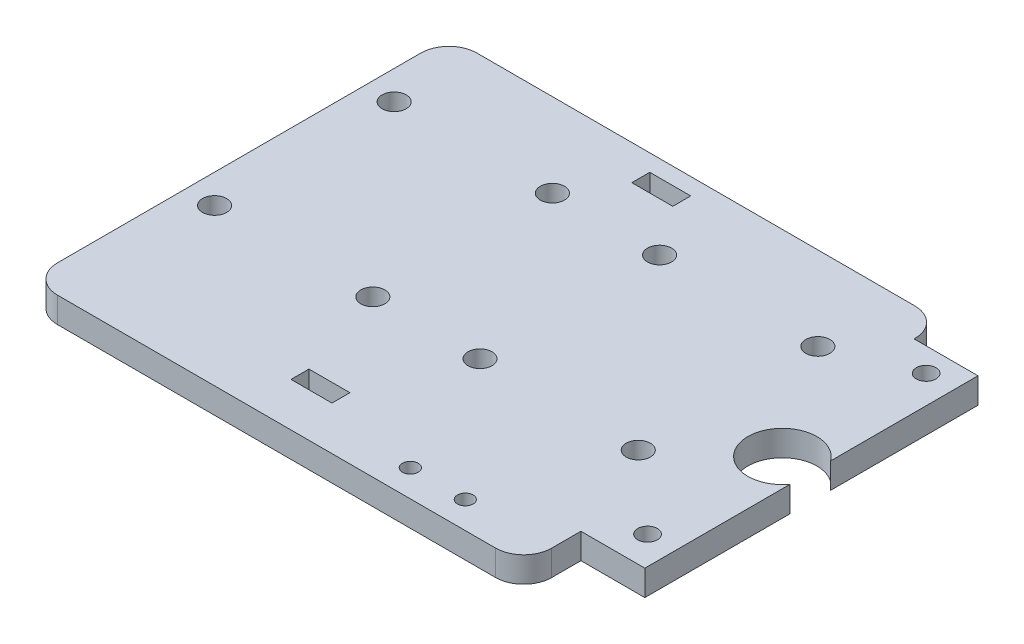
from build123d import *

# Parameters (mm, degrees)
SKETCH1_R           = 2.15
SKETCH1_R_2         = 6.15
SKETCH1_R_3         = 1.75
SKETCH1_R_4         = 1.4
SKETCH1_W           = 7.3
SKETCH1_H           = 3.2
BOSS_EXTRUDE1_DEPTH = 4.55
SKETCH2_W           = 30.597245163
SKETCH2_H           = 76.240319195
CUT_EXTRUDE1_DEPTH  = 5.55


with BuildPart() as part:
    # Sketch1 → Boss-Extrude1 (new body)
    with BuildSketch(Plane(origin=(0, 0, 0), x_dir=(1, 0, 0), z_dir=(0, 1, 0))):
        with BuildLine():
            Line((5, 0), (83.06, 0))
            ThreePointArc((83.06, 0), (86.595533906, 1.464466094), (88.06, 5))
            Line((88.06, 5), (88.06, 10.2))
            Line((88.06, 10.2), (109.36, 10.2))
            ThreePointArc((109.36, 10.2), (112.895533906, 11.664466094), (114.36, 15.2))
            Line((114.36, 15.2), (114.36, 64.57))
            ThreePointArc((114.36, 64.57), (112.895533906, 68.105533906), (109.36, 69.57))
            Line((109.36, 69.57), (88.06, 69.57))
            Line((88.06, 69.57), (88.06, 69.73))
            ThreePointArc((88.06, 69.73), (86.595533906, 73.265533906), (83.06, 74.73))
            Line((83.06, 74.73), (5, 74.73))
            ThreePointArc((5, 74.73), (1.464466094, 73.265533906), (0, 69.73))
            Line((0, 69.73), (0, 5))
            ThreePointArc((0, 5), (1.464466094, 1.464466094), (5, 0))
        make_face()
        with Locations((5.15, 59.83)):
            Circle(SKETCH1_R, mode=Mode.SUBTRACT)
        with Locations((33.35, 59.83)):
            Circle(SKETCH1_R, mode=Mode.SUBTRACT)
        with Locations((52.45, 59.83)):
            Circle(SKETCH1_R, mode=Mode.SUBTRACT)
        with Locations((80.65, 59.83)):
            Circle(SKETCH1_R, mode=Mode.SUBTRACT)
        with Locations((5.15, 27.83)):
            Circle(SKETCH1_R, mode=Mode.SUBTRACT)
        with Locations((33.35, 27.83)):
            Circle(SKETCH1_R, mode=Mode.SUBTRACT)
        with Locations((52.45, 27.83)):
            Circle(SKETCH1_R, mode=Mode.SUBTRACT)
        with Locations((80.65, 27.83)):
            Circle(SKETCH1_R, mode=Mode.SUBTRACT)
        with Locations((94.47, 39.69)):
            Circle(SKETCH1_R_2, mode=Mode.SUBTRACT)
        with Locations((94.45, 65.33)):
            Circle(SKETCH1_R_3, mode=Mode.SUBTRACT)
        with Locations((94.45, 15.69)):
            Circle(SKETCH1_R_3, mode=Mode.SUBTRACT)
        with Locations((63.06, 4.8)):
            Circle(SKETCH1_R_4, mode=Mode.SUBTRACT)
        with Locations((72.86, 4.8)):
            Circle(SKETCH1_R_4, mode=Mode.SUBTRACT)
        with Locations((42.45, 70.13)):
            Rectangle(SKETCH1_W, SKETCH1_H, mode=Mode.SUBTRACT)
        with Locations((42.45, 9.4)):
            Rectangle(SKETCH1_W, SKETCH1_H, mode=Mode.SUBTRACT)
    extrude(amount=BOSS_EXTRUDE1_DEPTH)

    # Sketch2 → Cut-Extrude1 (cut, through all)
    with BuildSketch(Plane(origin=(0, 4.55, 0), x_dir=(1, 0, 0), z_dir=(0, 1, 0))):
        with Locations((114.748622582, 38.120159597)):
            Rectangle(SKETCH2_W, SKETCH2_H)
    extrude(amount=-CUT_EXTRUDE1_DEPTH, mode=Mode.SUBTRACT)


solid = part.part
